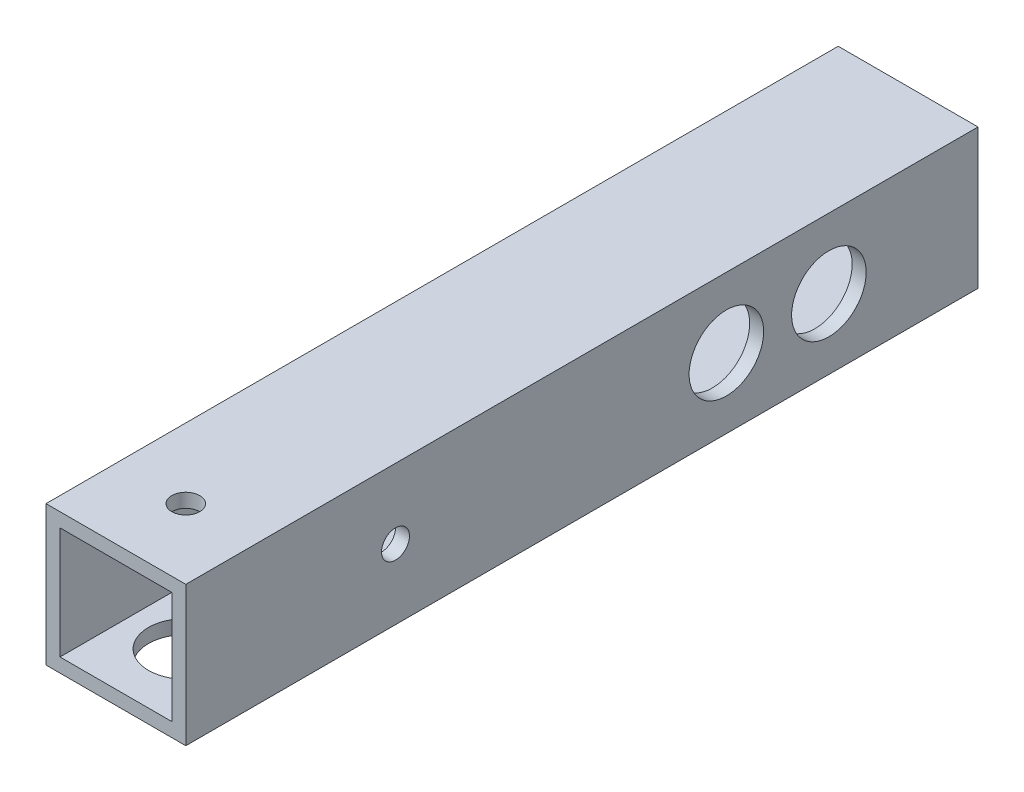
from build123d import *

# Parameters (mm, degrees)
SKETCH_1_W          = 15
SKETCH_1_H          = 15
SKETCH_1_W_2        = 12
SKETCH_1_H_2        = 12
EXTRUDE_2_DEPTH     = 85
SKETCH_3_R          = 1.5
CUT_EXTRUDE_2_DEPTH = 10
SKETCH_4_R          = 1.5
CUT_EXTRUDE_3_DEPTH = 10
SKETCH_5_R          = 4
CUT_EXTRUDE_4_DEPTH = 10
SKETCH_6_R          = 4
CUT_EXTRUDE_5_DEPTH = 10
SKETCH_7_R          = 3
CUT_EXTRUDE_6_DEPTH = 10
SKETCH_8_R          = 1.5
CUT_EXTRUDE_7_DEPTH = 10
SKETCH_9_R          = 1.5
CUT_EXTRUDE_8_DEPTH = 10
SKETCH_10_R         = 4
CUT_EXTRUDE_9_DEPTH = 10


with BuildPart() as part:
    # ｽｹｯﾁ1 → ﾎﾞｽ - 押し出し2 (new body)
    with BuildSketch(Plane.XY):
        with Locations((0.489915859, 0.232626086)):
            Rectangle(SKETCH_1_W, SKETCH_1_H)
        with Locations((0.489915859, 0.232626086)):
            Rectangle(SKETCH_1_W_2, SKETCH_1_H_2, mode=Mode.SUBTRACT)
    extrude(amount=EXTRUDE_2_DEPTH)

    # ｽｹｯﾁ3 → ｶｯﾄ - 押し出し2 (cut)
    with BuildSketch(Plane(origin=(0, 7.732626086, 0), x_dir=(1, 0, 0), z_dir=(0, 1, 0))):
        with Locations((0.489915859, -77.5)):
            Circle(SKETCH_3_R)
    extrude(amount=-CUT_EXTRUDE_2_DEPTH, mode=Mode.SUBTRACT)

    # ｽｹｯﾁ4 → ｶｯﾄ - 押し出し3 (cut)
    with BuildSketch(Plane(origin=(7.989915859, 0, 0), x_dir=(0, 0, -1), z_dir=(1, 0, 0))):
        with Locations((-62.5, 0.232626086)):
            Circle(SKETCH_4_R)
    extrude(amount=-CUT_EXTRUDE_3_DEPTH, mode=Mode.SUBTRACT)

    # ｽｹｯﾁ5 → ｶｯﾄ - 押し出し4 (cut)
    with BuildSketch(Plane.XZ.offset(7.267373914)):
        with Locations((0.489915859, 77.5)):
            Circle(SKETCH_5_R)
    extrude(amount=-CUT_EXTRUDE_4_DEPTH, mode=Mode.SUBTRACT)

    # ｽｹｯﾁ6 → ｶｯﾄ - 押し出し5 (cut)
    with BuildSketch(Plane.ZY.offset(7.010084141)):
        with Locations((62.5, 0.232626086)):
            Circle(SKETCH_6_R)
    extrude(amount=-CUT_EXTRUDE_5_DEPTH, mode=Mode.SUBTRACT)

    # ｽｹｯﾁ7 → ｶｯﾄ - 押し出し6 (cut)
    with BuildSketch(Plane.ZY.offset(7.010084141)):
        with Locations((16, 0.232626086)):
            Circle(SKETCH_7_R)
    extrude(amount=-CUT_EXTRUDE_6_DEPTH, mode=Mode.SUBTRACT)

    # ｽｹｯﾁ8 → ｶｯﾄ - 押し出し7 (cut)
    with BuildSketch(Plane.ZY.offset(7.010084141)):
        with Locations((5, 0.232626086)):
            Circle(SKETCH_8_R)
    extrude(amount=-CUT_EXTRUDE_7_DEPTH, mode=Mode.SUBTRACT)

    # ｽｹｯﾁ9 → ｶｯﾄ - 押し出し8 (cut)
    with BuildSketch(Plane.ZY.offset(7.010084141)):
        with Locations((27, 0.232626086)):
            Circle(SKETCH_9_R)
    extrude(amount=-CUT_EXTRUDE_8_DEPTH, mode=Mode.SUBTRACT)

    # ｽｹｯﾁ10 → ｶｯﾄ - 押し出し9 (cut)
    with BuildSketch(Plane(origin=(7.989915859, 0, 0), x_dir=(0, 0, -1), z_dir=(1, 0, 0))):
        with Locations((-16, 0.232626086)):
            Circle(SKETCH_10_R)
        with Locations((-27, 0.232626086)):
            Circle(SKETCH_10_R)
    extrude(amount=-CUT_EXTRUDE_9_DEPTH, mode=Mode.SUBTRACT)


solid = part.part
